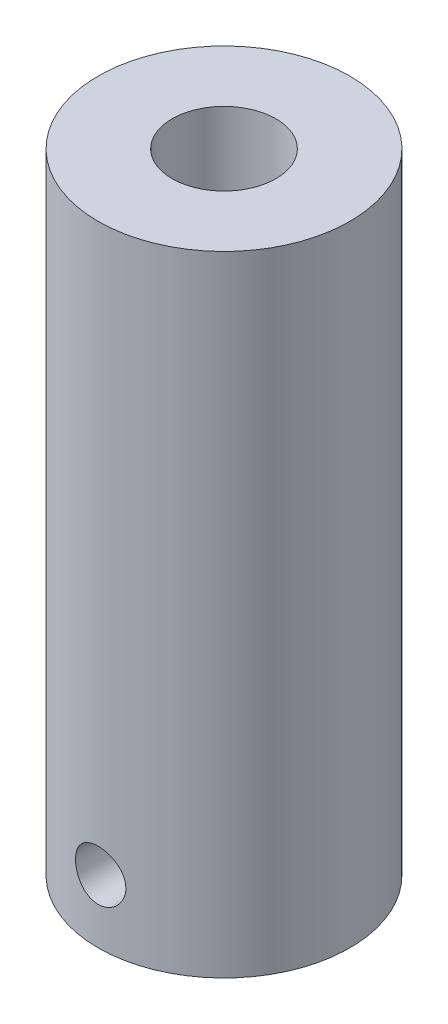
from build123d import *

# Parameters (mm, degrees)
CROQUIS1_R              = 4
CROQUIS1_R_2            = 2
SALIENTE_EXTRUIR1_DEPTH = 25.4
CROQUIS2_R              = 30
SALIENTE_EXTRUIR2_DEPTH = 5
CROQUIS3_R              = 2
CORTAR_EXTRUIR1_DEPTH   = 7.5
CROQUIS7_R              = 3.5
CORTAR_EXTRUIR3_DEPTH   = 3
CROQUIS8_W              = 62.698346187
CROQUIS8_H              = 3
CORTAR_EXTRUIR5_DEPTH   = 15
CROQUIS1_3_R            = 2
CORTAR_EXTRUIR6_DEPTH   = 7.4
CROQUIS6_R              = 0.8
CORTAR_EXTRUIR7_DEPTH   = 10
CROQUIS10_R             = 30
CORTAR_EXTRUIR8_DEPTH   = 7.4
CROQUIS11_R             = 1.65
CORTAR_EXTRUIR9_DEPTH   = 10


with BuildPart() as part:
    # Croquis1 → Saliente-Extruir1 (new body)
    with BuildSketch(Plane(origin=(0, 0, 0), x_dir=(1, 0, 0), z_dir=(0, 1, 0))):
        with Locations(Location((0, 0, 0), (0, 0, 270))):
            Circle(CROQUIS1_R)
        Circle(CROQUIS1_R_2, mode=Mode.SUBTRACT)
        Circle(CROQUIS1_R_2)
    extrude(amount=SALIENTE_EXTRUIR1_DEPTH)

    # Croquis2 → Saliente-Extruir2 (add)
    with BuildSketch(Plane(origin=(0, 25.4, 0), x_dir=(1, 0, 0), z_dir=(0, 1, 0))):
        with Locations(Location((0, 0, 0), (0, 0, 270))):
            Circle(CROQUIS2_R)
    extrude(amount=SALIENTE_EXTRUIR2_DEPTH)

    # Croquis3 → Cortar-Extruir1 (cut)
    with BuildSketch(Plane(origin=(0, 30.4, 0), x_dir=(1, 0, 0), z_dir=(0, 1, 0))):
        with Locations(Location((0, 10, 0), (0, 0, 270))):
            Circle(CROQUIS3_R)
        with Locations(Location((10, 0, 0), (0, 0, 270))):
            Circle(CROQUIS3_R)
        with Locations(Location((0, -10, 0), (0, 0, 270))):
            Circle(CROQUIS3_R)
        with Locations(Location((-10, 0, 0), (0, 0, 270))):
            Circle(CROQUIS3_R)
    extrude(amount=-CORTAR_EXTRUIR1_DEPTH, mode=Mode.SUBTRACT)

    # Croquis7 → Cortar-Extruir3 (cut)
    with BuildSketch(Plane.XZ):
        with Locations(Location((0, 0, 0), (0, 0, 270))):
            Circle(CROQUIS7_R)
    extrude(amount=-CORTAR_EXTRUIR3_DEPTH, mode=Mode.SUBTRACT)

    # Croquis8 → Cortar-Extruir5 (cut, symmetric)
    with BuildSketch(Plane(origin=(0, 0, 0), x_dir=(0, 0, -1), z_dir=(1, 0, 0))):
        with Locations((4.276742622, 1.5)):
            Rectangle(CROQUIS8_W, CROQUIS8_H)
    extrude(amount=CORTAR_EXTRUIR5_DEPTH, both=True, mode=Mode.SUBTRACT)

    # Croquis1_3 → Cortar-Extruir6 (cut)
    with BuildSketch(Plane(origin=(0, 0, 0), x_dir=(1, 0, 0), z_dir=(0, 1, 0))):
        with Locations(Location((0, 0, 0), (0, 0, 90))):
            Circle(CROQUIS1_3_R)
    extrude(amount=CORTAR_EXTRUIR6_DEPTH, mode=Mode.SUBTRACT)

    # Croquis6 → Cortar-Extruir7 (cut)
    with BuildSketch(Plane.XY):
        with Locations(Location((0, 5, 0), (0, 0, 180))):
            Circle(CROQUIS6_R)
    extrude(amount=CORTAR_EXTRUIR7_DEPTH, mode=Mode.SUBTRACT)

    # Croquis10 → Cortar-Extruir8 (cut)
    with BuildSketch(Plane(origin=(0, 30.4, 0), x_dir=(1, 0, 0), z_dir=(0, 1, 0))):
        Circle(CROQUIS10_R)
    extrude(amount=-CORTAR_EXTRUIR8_DEPTH, mode=Mode.SUBTRACT)

    # Croquis11 → Cortar-Extruir9 (cut)
    with BuildSketch(Plane(origin=(0, 23, 0), x_dir=(1, 0, 0), z_dir=(0, 1, 0))):
        with Locations(Location((0, 0, 0), (0, 0, 270))):
            Circle(CROQUIS11_R)
    extrude(amount=-CORTAR_EXTRUIR9_DEPTH, mode=Mode.SUBTRACT)


solid = part.part
